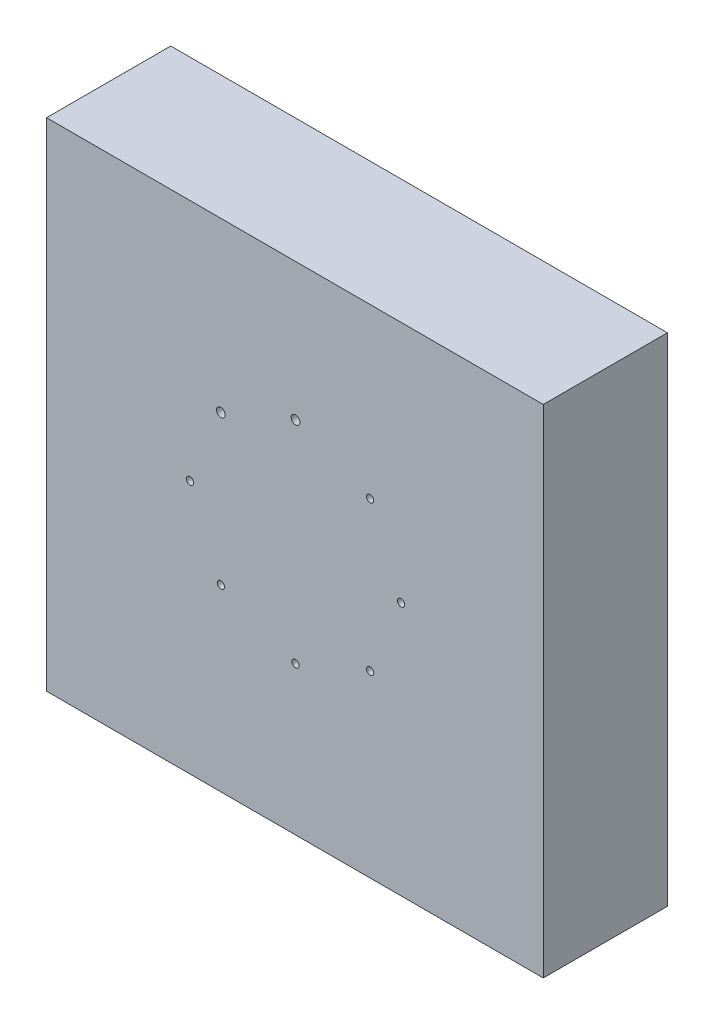
from build123d import *

# Parameters (mm, degrees)
SKETCH_1_W          = 200
SKETCH_1_H          = 200
EXTRUDE_1_DEPTH     = 50
SKETCH_7_R          = 1.45
SKETCH_7_R_2        = 1.450147074
SKETCH_7_R_3        = 1.449615697
SKETCH_7_R_4        = 1.75
SKETCH_7_R_5        = 1.439370264
SKETCH_7_R_6        = 1.750543486
CUT_EXTRUDE_2_DEPTH = 5


with BuildPart() as part:
    # 草图1 → 凸台-拉伸1 (new body)
    with BuildSketch(Plane.XY):
        Rectangle(SKETCH_1_W, SKETCH_1_H)
    extrude(amount=EXTRUDE_1_DEPTH)

    # 草图7 → 切除-拉伸2 (cut)
    with BuildSketch(Plane.XY.offset(50)):
        with Locations((0.25, -40.25)):
            Circle(SKETCH_7_R)
        with Locations((-29.8020382, -27.8020382)):
            Circle(SKETCH_7_R_2)
        with Locations((-42.25, 2.25)):
            Circle(SKETCH_7_R_3)
        with Locations((-29.8020382, 32.3020382)):
            Circle(SKETCH_7_R_4)
        with Locations((42.750271742, 2.249728256)):
            Circle(SKETCH_7_R)
        with Locations((30.302117792, -27.802230352)):
            Circle(SKETCH_7_R)
        with Locations((30.302038201, 32.3020382)):
            Circle(SKETCH_7_R_5)
        with Locations((0.250543486, 44.749999998)):
            Circle(SKETCH_7_R_6)
    extrude(amount=-CUT_EXTRUDE_2_DEPTH, mode=Mode.SUBTRACT)


solid = part.part
